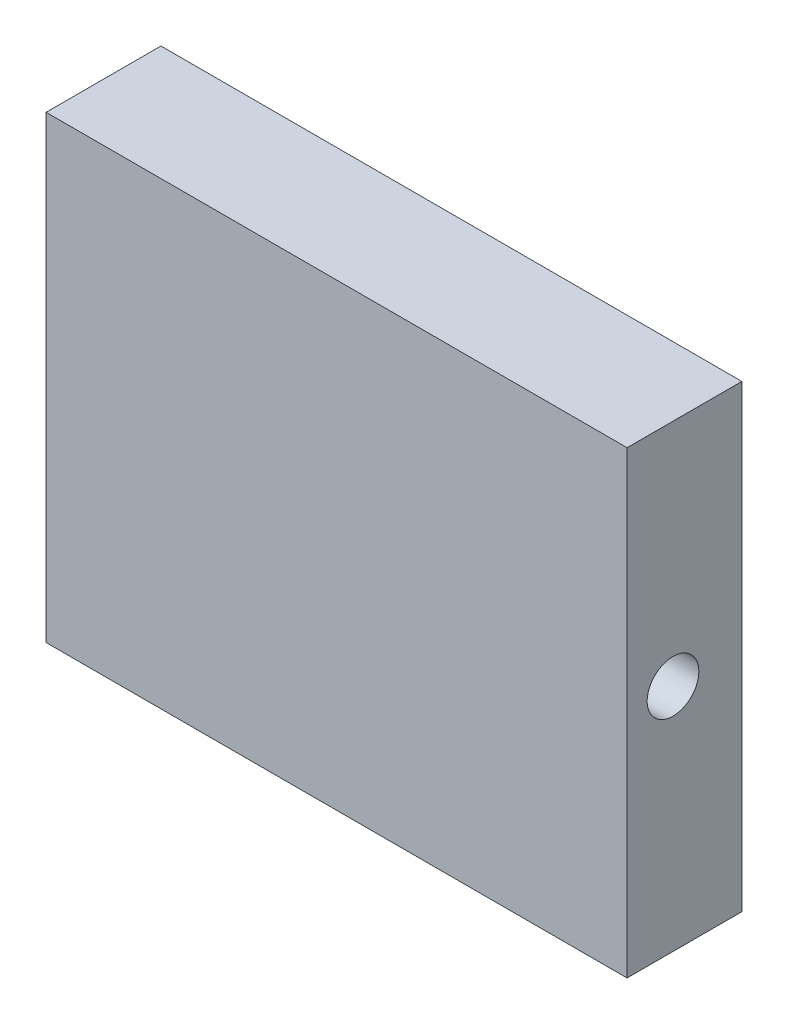
from build123d import *

# Parameters (mm, degrees)
SKETCH1_W          = 50.6
SKETCH1_H          = 40
EXTRUDE1_DEPTH     = 10
SKETCH2_R          = 2.25
CUT_EXTRUDE1_DEPTH = 10


with BuildPart() as part:
    # Sketch1 → Extrude1 (new body)
    with BuildSketch(Plane.XY):
        with Locations((25.3, 20)):
            Rectangle(SKETCH1_W, SKETCH1_H)
    extrude(amount=EXTRUDE1_DEPTH)

    # Sketch2 → Cut-Extrude1 (cut)
    with BuildSketch(Plane(origin=(50.6, 0, 0), x_dir=(0, 0, -1), z_dir=(1, 0, 0))):
        with Locations((-6, 20)):
            Circle(SKETCH2_R)
    extrude(amount=-CUT_EXTRUDE1_DEPTH, mode=Mode.SUBTRACT)


solid = part.part
